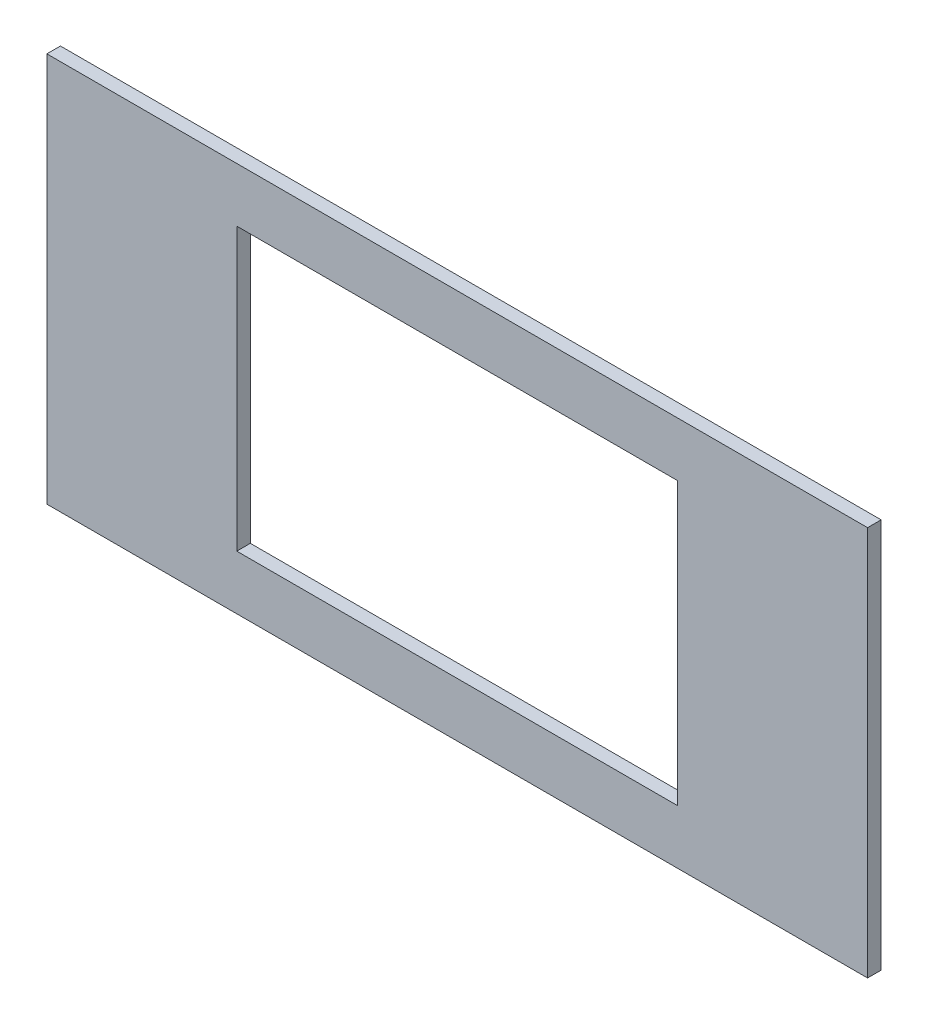
from build123d import *

# Parameters (mm, degrees)
SKETCH_1_W      = 242
SKETCH_1_H      = 115
SKETCH_1_W_2    = 130
SKETCH_1_H_2    = 83
EXTRUDE_1_DEPTH = 4


with BuildPart() as part:
    # 草图1 → 凸台-拉伸1 (new body)
    with BuildSketch(Plane.XY):
        with Locations((21.960072595, 8.709618875)):
            Rectangle(SKETCH_1_W, SKETCH_1_H)
        with Locations((21.960072595, 8.709618875)):
            Rectangle(SKETCH_1_W_2, SKETCH_1_H_2, mode=Mode.SUBTRACT)
    extrude(amount=EXTRUDE_1_DEPTH)


solid = part.part
